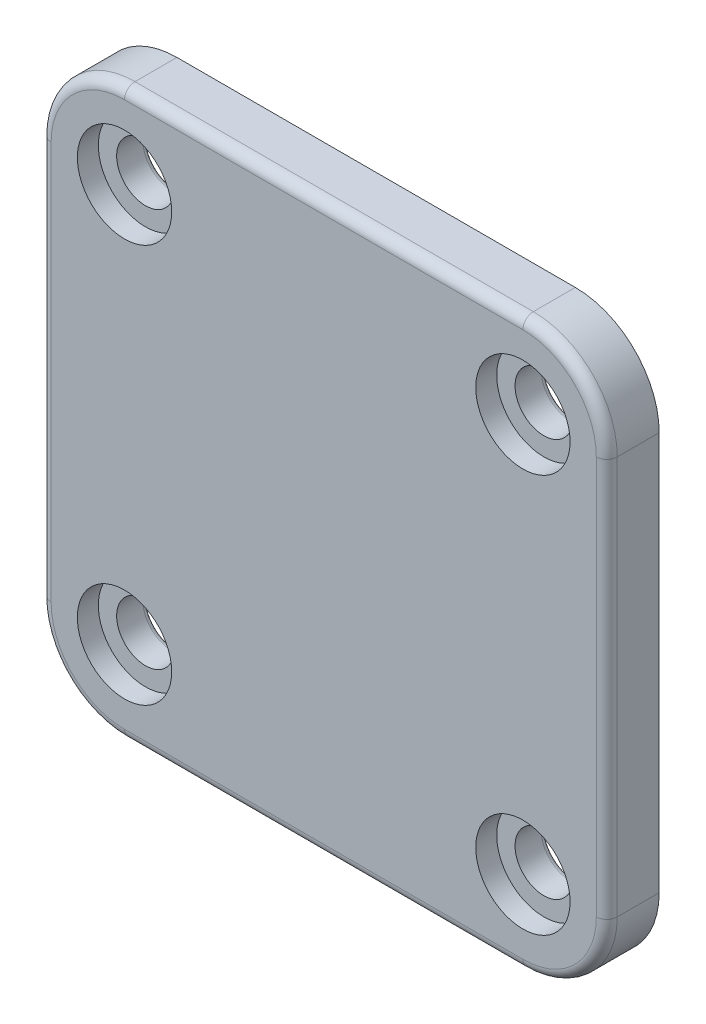
from build123d import *

# Parameters (mm, degrees)
SKETCH1_W           = 54
SKETCH1_H           = 54
SKETCH1_R           = 2.75
BOSS_EXTRUDE1_DEPTH = 5
FILLET1_R           = 8
FILLET2_R           = 0.5
FILLET3_R           = 1
SKETCH2_R           = 4.5
CUT_EXTRUDE2_DEPTH  = 2


with BuildPart() as part:
    # Sketch1 → Boss-Extrude1 (new body)
    with BuildSketch(Plane.XY):
        Rectangle(SKETCH1_W, SKETCH1_H)
        with Locations((-19, 19)):
            Circle(SKETCH1_R, mode=Mode.SUBTRACT)
        with Locations((19, 19)):
            Circle(SKETCH1_R, mode=Mode.SUBTRACT)
        with Locations((19, -19)):
            Circle(SKETCH1_R, mode=Mode.SUBTRACT)
        with Locations((-19, -19)):
            Circle(SKETCH1_R, mode=Mode.SUBTRACT)
    extrude(amount=BOSS_EXTRUDE1_DEPTH)

    # Fillet1
    fillet1_edges = [part.edges().sort_by_distance(p)[0] for p in [
        (-27, 27, 2.5),
        (27, 27, 2.5),
        (27, -27, 2.5),
        (-27, -27, 2.5),
    ]]
    fillet(fillet1_edges, radius=FILLET1_R)

    # Fillet2
    fillet2_edges = [part.edges().sort_by_distance(p)[0] for p in [
        (-21.75, 19, 0),
        (-21.75, 19, 5),
        (16.25, 19, 0),
        (16.25, 19, 5),
        (16.25, -19, 0),
        (16.25, -19, 5),
        (-21.75, -19, 0),
        (-21.75, -19, 5),
    ]]
    fillet(fillet2_edges, radius=FILLET2_R)

    # Fillet3
    fillet3_edges = [part.edges().sort_by_distance(p)[0] for p in [
        (-27, 0, 5),
        (0, 27, 5),
        (0, -27, 5),
        (27, 0, 5),
        (24.656854249, 24.656854249, 5),
        (-24.656854249, -24.656854249, 5),
        (24.656854249, -24.656854249, 5),
        (-24.656854249, 24.656854249, 5),
    ]]
    fillet(fillet3_edges, radius=FILLET3_R)

    # Sketch2 → Cut-Extrude2 (cut)
    with BuildSketch(Plane.XY.offset(5)):
        with Locations((-19, 19)):
            Circle(SKETCH2_R)
        with Locations((19, 19)):
            Circle(SKETCH2_R)
        with Locations((19, -19)):
            Circle(SKETCH2_R)
        with Locations((-19, -19)):
            Circle(SKETCH2_R)
    extrude(amount=-CUT_EXTRUDE2_DEPTH, mode=Mode.SUBTRACT)


solid = part.part
